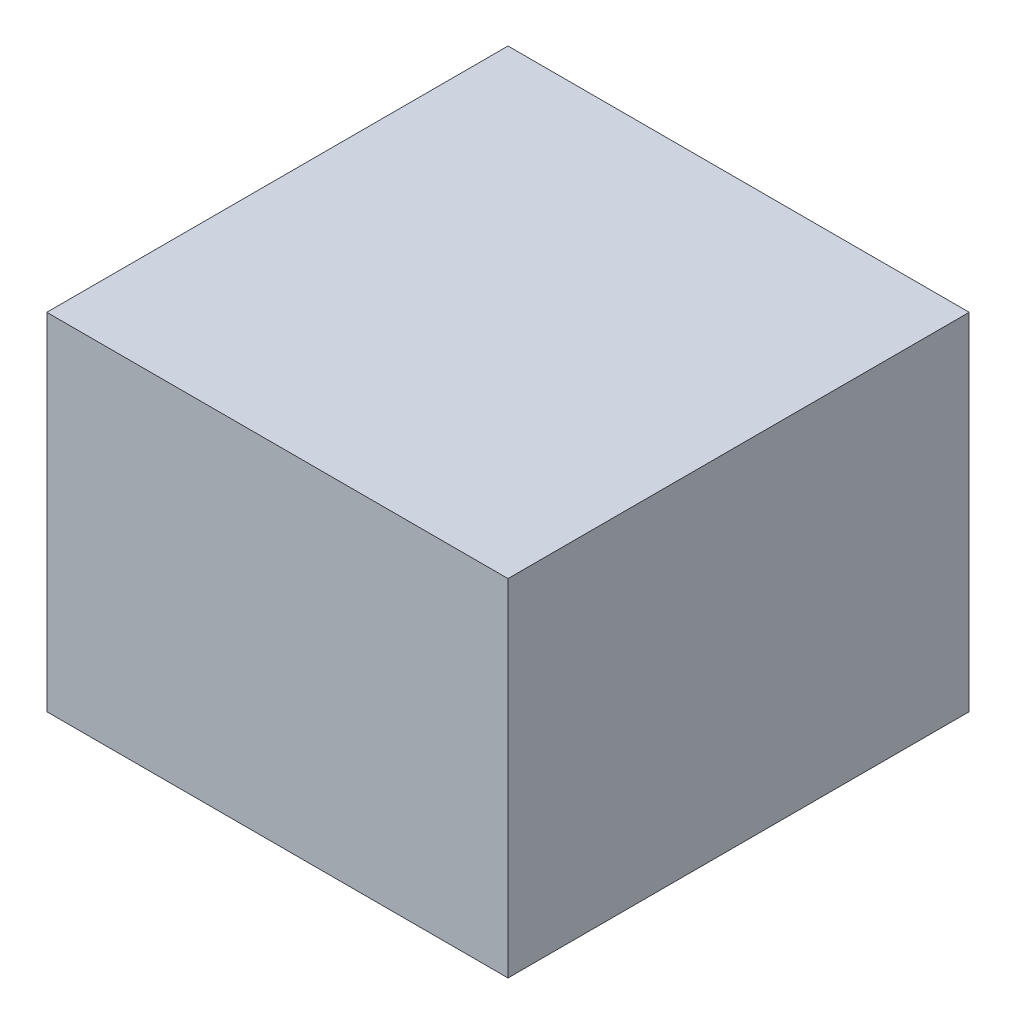
from build123d import *

# Parameters (mm, degrees)
SKETCH1_W           = 20
SKETCH1_H           = 20
BOSS_EXTRUDE1_DEPTH = 15


with BuildPart() as part:
    # Sketch1 → Boss-Extrude1 (new body)
    with BuildSketch(Plane(origin=(0, 0, 0), x_dir=(1, 0, 0), z_dir=(0, 1, 0))):
        Rectangle(SKETCH1_W, SKETCH1_H)
    extrude(amount=BOSS_EXTRUDE1_DEPTH)


solid = part.part
